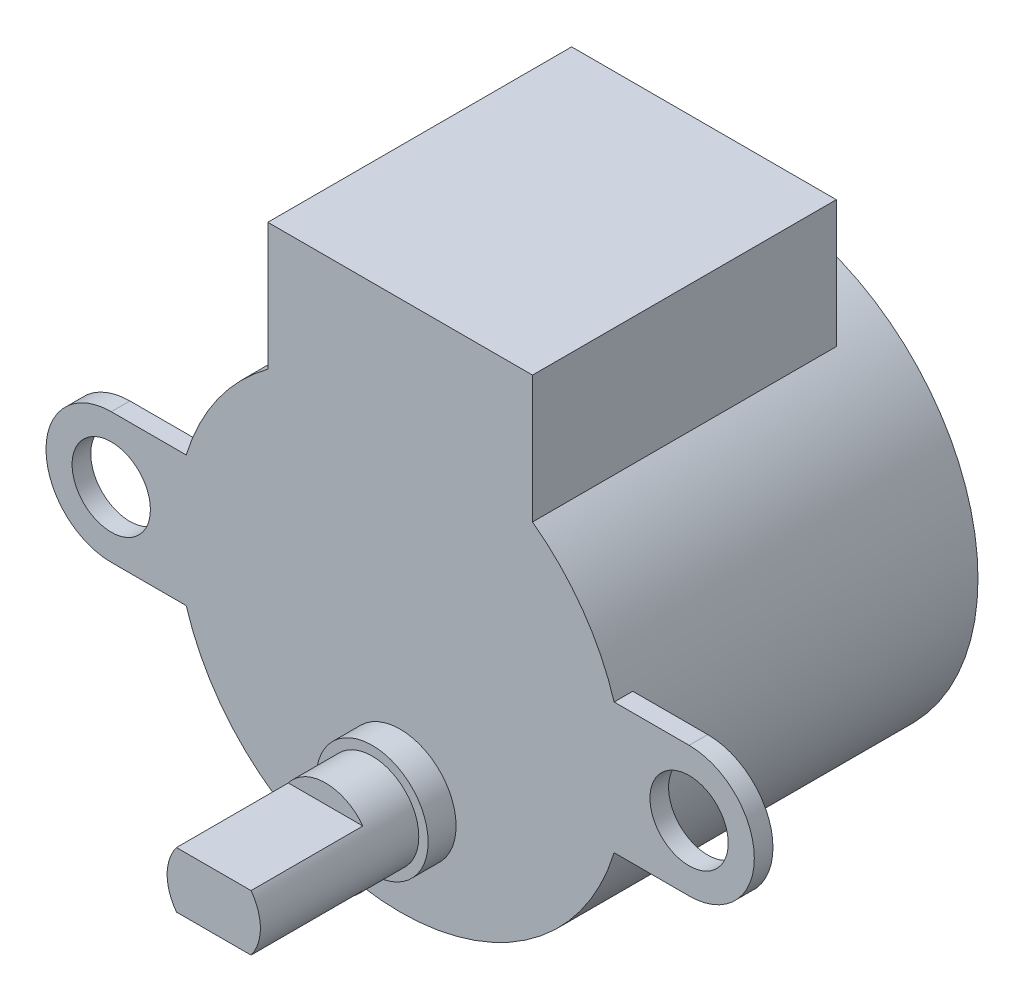
from build123d import *

# Parameters (mm, degrees)
BOSS_EXTRUDE1_DEPTH = 19
CUT_EXTRUDE1_DEPTH  = 2.7
SKETCH3_R           = 2.1
BOSS_EXTRUDE2_DEPTH = 1
SKETCH4_R           = 3
BOSS_EXTRUDE3_DEPTH = 1.5
SKETCH5_R           = 2.5
BOSS_EXTRUDE5_DEPTH = 8.5
CUT_EXTRUDE2_DEPTH  = 6


with BuildPart() as part:
    # Sketch1 → Boss-Extrude1 (new body)
    with BuildSketch(Plane.XY):
        with BuildLine():
            Line((-7.1, 9.674192473), (-7.1, 16.5))
            Line((-7.1, 16.5), (7.1, 16.5))
            Line((7.1, 16.5), (7.1, 9.674192473))
            ThreePointArc((7.1, 9.674192473), (0, -12), (-7.1, 9.674192473))
        make_face()
    extrude(amount=BOSS_EXTRUDE1_DEPTH)

    # Sketch2 → Cut-Extrude1 (cut)
    with BuildSketch(Plane(origin=(0, 0, 0), x_dir=(-1, 0, 0), z_dir=(0, 0, -1))):
        with BuildLine():
            Line((7.1, 16.5), (7.1, 9.674192473))
            ThreePointArc((7.1, 9.674192473), (0, 12), (-7.1, 9.674192473))
            Line((-7.1, 9.674192473), (-7.1, 16.5))
            Line((-7.1, 16.5), (7.1, 16.5))
        make_face()
    extrude(amount=-CUT_EXTRUDE1_DEPTH, mode=Mode.SUBTRACT)

    # Sketch3 → Boss-Extrude2 (add)
    with BuildSketch(Plane.XY.offset(19)):
        with BuildLine():
            Line((-15.5, 3.5), (-11.478240283, 3.5))
            ThreePointArc((-11.478240283, 3.5), (-12, 0), (-11.478240283, -3.5))
            Line((-11.478240283, -3.5), (-15.5, -3.5))
            ThreePointArc((-15.5, -3.5), (-19, 0), (-15.5, 3.5))
        make_face()
        with Locations((-15.5, 0)):
            Circle(SKETCH3_R, mode=Mode.SUBTRACT)
        with BuildLine():
            Line((11.478240283, 3.5), (15.5, 3.5))
            ThreePointArc((15.5, 3.5), (19, 0), (15.5, -3.5))
            Line((15.5, -3.5), (11.478240283, -3.5))
            ThreePointArc((11.478240283, -3.5), (12, 0), (11.478240283, 3.5))
        make_face()
        with Locations((15.5, 0)):
            Circle(SKETCH3_R, mode=Mode.SUBTRACT)
    extrude(amount=-BOSS_EXTRUDE2_DEPTH)

    # Sketch4 → Boss-Extrude3 (add)
    with BuildSketch(Plane.XY.offset(19)):
        with Locations((0, -6.5)):
            Circle(SKETCH4_R)
    extrude(amount=BOSS_EXTRUDE3_DEPTH)

    # Sketch5 → Boss-Extrude5 (add)
    with BuildSketch(Plane.XY.offset(20.5)):
        with Locations((0, -6.5)):
            Circle(SKETCH5_R)
    extrude(amount=BOSS_EXTRUDE5_DEPTH)

    # Sketch7 → Cut-Extrude2 (cut)
    with BuildSketch(Plane.XY.offset(29)):
        with BuildLine():
            Line((-2, -5), (2, -5))
            ThreePointArc((2, -5), (0, -4), (-2, -5))
        make_face()
        with BuildLine():
            Line((-2, -8), (2, -8))
            ThreePointArc((2, -8), (0, -9), (-2, -8))
        make_face()
    extrude(amount=-CUT_EXTRUDE2_DEPTH, mode=Mode.SUBTRACT)


solid = part.part
